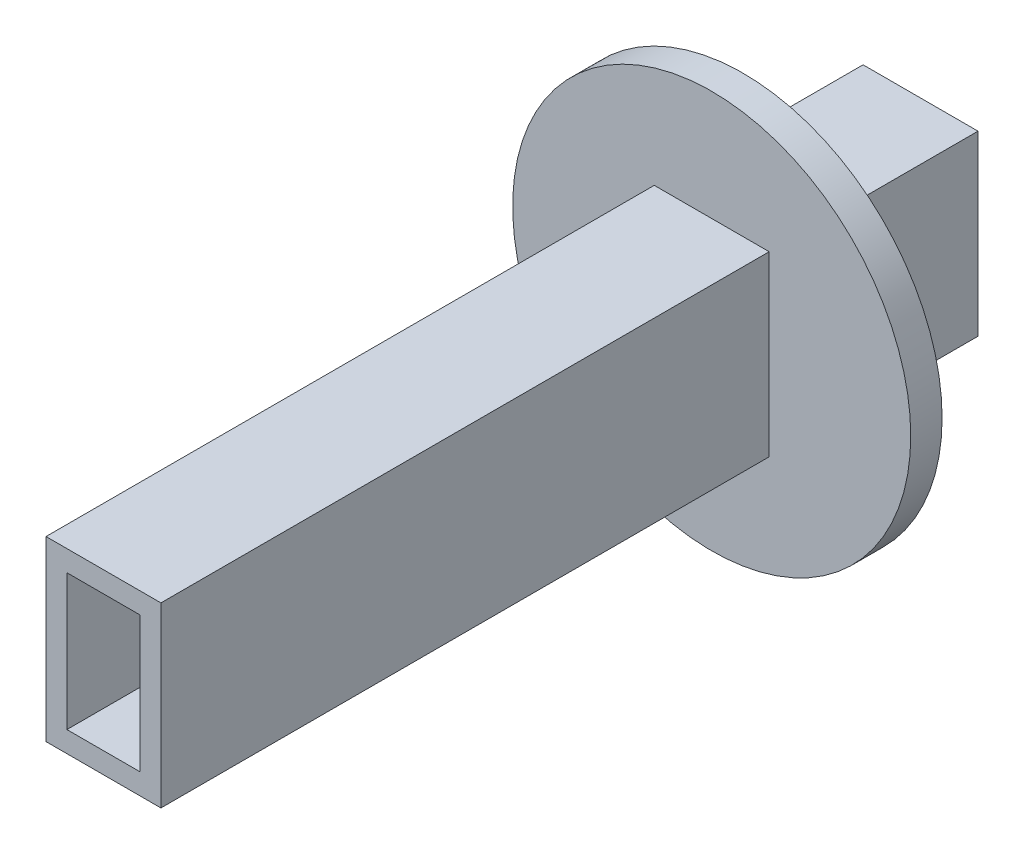
from build123d import *

# Parameters (mm, degrees)
SKETCH1_W           = 11
SKETCH1_H           = 17
SKETCH1_W_2         = 7
SKETCH1_H_2         = 13
BOSS_EXTRUDE1_DEPTH = 76.2
SKETCH2_W           = 11
SKETCH2_H           = 17
BOSS_EXTRUDE2_DEPTH = 2
SKETCH3_W           = 7
SKETCH3_H           = 11
CUT_EXTRUDE1_DEPTH  = 2
SKETCH4_R           = 19.05
SKETCH4_W           = 11
SKETCH4_H           = 17
BOSS_EXTRUDE3_DEPTH = 3
SKETCH5_R           = 12.7
SKETCH5_W           = 11
SKETCH5_H           = 17
BOSS_EXTRUDE4_DEPTH = 2.54


with BuildPart() as part:
    # Sketch1 → Boss-Extrude1 (new body)
    with BuildSketch(Plane.XY):
        with Locations((3.5, 6.5)):
            Rectangle(SKETCH1_W, SKETCH1_H)
        with Locations((3.5, 6.5)):
            Rectangle(SKETCH1_W_2, SKETCH1_H_2, mode=Mode.SUBTRACT)
    extrude(amount=BOSS_EXTRUDE1_DEPTH)

    # Sketch2 → Boss-Extrude2 (add)
    with BuildSketch(Plane(origin=(0, 0, 0), x_dir=(-1, 0, 0), z_dir=(0, 0, -1))):
        with Locations((-3.5, 6.5)):
            Rectangle(SKETCH2_W, SKETCH2_H)
    extrude(amount=BOSS_EXTRUDE2_DEPTH)

    # Sketch3 → Cut-Extrude1 (cut)
    with BuildSketch(Plane(origin=(0, -2, 0), x_dir=(-1, 0, 0), z_dir=(0, -1, 0))):
        with Locations((-3.5, -5.5)):
            Rectangle(SKETCH3_W, SKETCH3_H)
    extrude(amount=-CUT_EXTRUDE1_DEPTH, mode=Mode.SUBTRACT)

    # Sketch4 → Boss-Extrude3 (add)
    with BuildSketch(Plane.XY.offset(14.986)):
        with Locations((3.5, 6.5)):
            Circle(SKETCH4_R)
        with Locations((3.5, 6.5)):
            Rectangle(SKETCH4_W, SKETCH4_H, mode=Mode.SUBTRACT)
    extrude(amount=BOSS_EXTRUDE3_DEPTH)

    # Sketch5 → Boss-Extrude4 (add)
    with BuildSketch(Plane(origin=(0, 0, 14.986), x_dir=(-1, 0, 0), z_dir=(0, 0, -1))):
        with Locations((-3.5, 6.5)):
            Circle(SKETCH5_R)
        with Locations((-3.5, 6.5)):
            Rectangle(SKETCH5_W, SKETCH5_H, mode=Mode.SUBTRACT)
    extrude(amount=BOSS_EXTRUDE4_DEPTH)


solid = part.part
